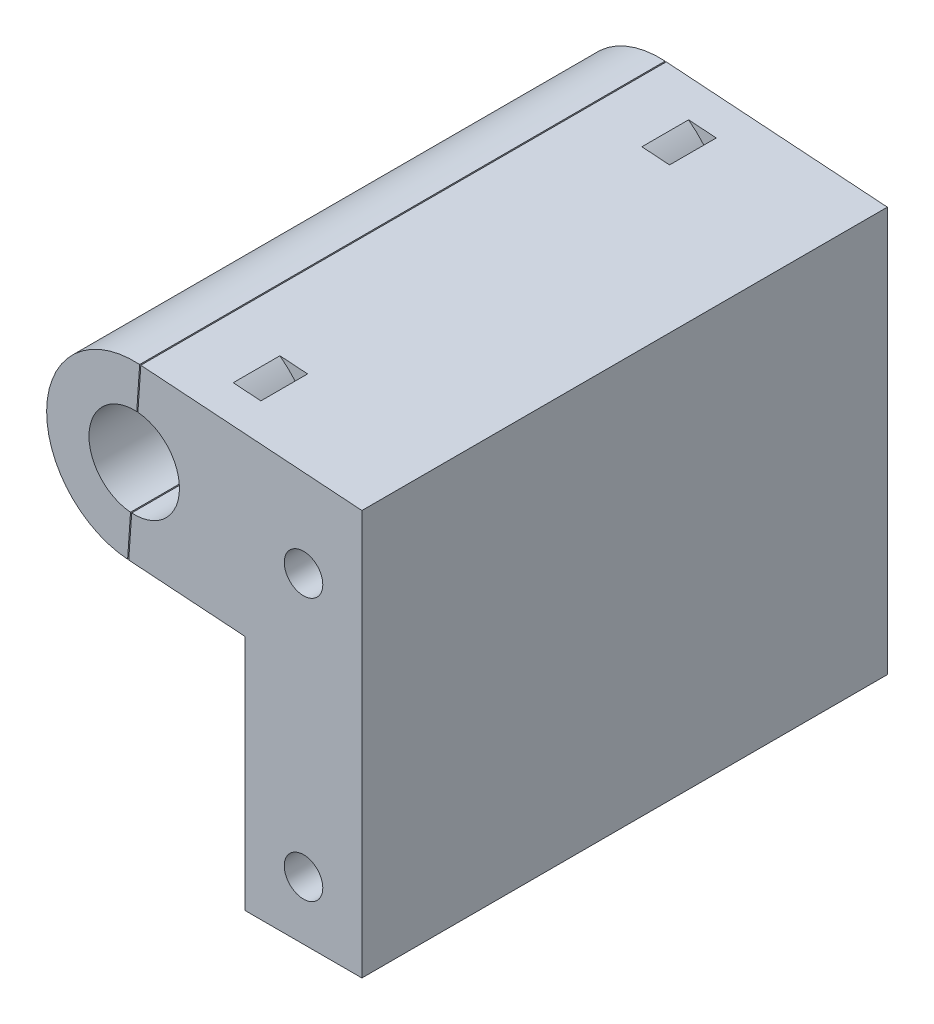
from build123d import *

# Parameters (mm, degrees)
BOSS_EXTRUDE1_DEPTH   = 45
CUT_EXTRUDE1_START    = -5
CUT_EXTRUDE1_DEPTH    = 2
M4X0_7_TAPPED_HOLE1_D = 3.3
SKETCH5_R             = 7.5
BOSS_EXTRUDE2_DEPTH   = 45
SKETCH6_R             = 3.875
CUT_EXTRUDE2_DEPTH    = 46
CUT_EXTRUDE3_DEPTH    = 46


with BuildPart() as part:
    # Sketch1 → Boss-Extrude1 (new body)
    with BuildSketch(Plane.XY):
        with BuildLine():
            Line((-182.516015687, 162.517772537), (-172.5, 161.827012834))
            Line((-172.5, 161.827012834), (-172.5, 141.5))
            Line((-172.5, 141.5), (-162.5, 141.5))
            Line((-162.5, 141.5), (-162.5, 176.172987166))
            Line((-162.5, 176.172987166), (-181.483984313, 177.482227463))
            ThreePointArc((-181.483984313, 177.482227463), (-174.517772537, 169.483984313), (-182.516015687, 162.517772537))
        make_face()
    extrude(amount=BOSS_EXTRUDE1_DEPTH)

    # Sketch2 → Cut-Extrude1 (cut, symmetric)
    with BuildSketch(Plane(origin=(0, 0, 0), x_dir=(-1, 0, 0), z_dir=(0, 0, -1)).offset(CUT_EXTRUDE1_START)):
        with BuildLine():
            ThreePointArc((176.520836095, 177.139941379), (173.021327044, 169.380781175), (177.552867469, 162.175486453))
            ThreePointArc((177.552867469, 162.175486453), (177.834315887, 161.15284928), (176.811678714, 160.871400862))
            ThreePointArc((176.811678714, 160.871400862), (171.524881552, 169.277578038), (175.60764211, 178.329931609))
            ThreePointArc((175.60764211, 178.329931609), (176.659234217, 178.191533486), (176.520836095, 177.139941379))
        make_face()
    cut_extrude1 = extrude(amount=CUT_EXTRUDE1_DEPTH, both=True, mode=Mode.SUBTRACT)

    # Mirror1: Cut-Extrude1 across plane
    add(cut_extrude1.mirror(Plane(origin=(0, 0, 22.5), x_dir=(1, 0, 0), z_dir=(0, 0, -1))), mode=Mode.SUBTRACT)

    # M4x0.7 Tapped Hole1 (through all)
    with Locations(Plane.XY.offset(45)):
        with Locations((-167.5, 169), (-167.5, 146.5)):
            Hole(M4X0_7_TAPPED_HOLE1_D / 2)

    # Sketch5 → Boss-Extrude2 (add, through all)
    with BuildSketch(Plane.XY.offset(45)):
        with Locations((-182, 170)):
            Circle(SKETCH5_R)
    extrude(amount=-BOSS_EXTRUDE2_DEPTH)

    # Sketch6 → Cut-Extrude2 (cut, through all)
    with BuildSketch(Plane.XY.offset(45)):
        with Locations((-182, 170)):
            Circle(SKETCH6_R)
    extrude(amount=-CUT_EXTRUDE2_DEPTH, mode=Mode.SUBTRACT)

    # Sketch7 → Cut-Extrude3 (cut, through all)
    with BuildSketch(Plane(origin=(0, 0, 0), x_dir=(-1, 0, 0), z_dir=(0, 0, -1))):
        Polygon((181.434102796, 177.478787359), (182.466134171, 162.514332432), (182.565897204, 162.521212641), (181.533865829, 177.485667568), align=None)
    extrude(amount=-CUT_EXTRUDE3_DEPTH, mode=Mode.SUBTRACT)


solid = part.part
